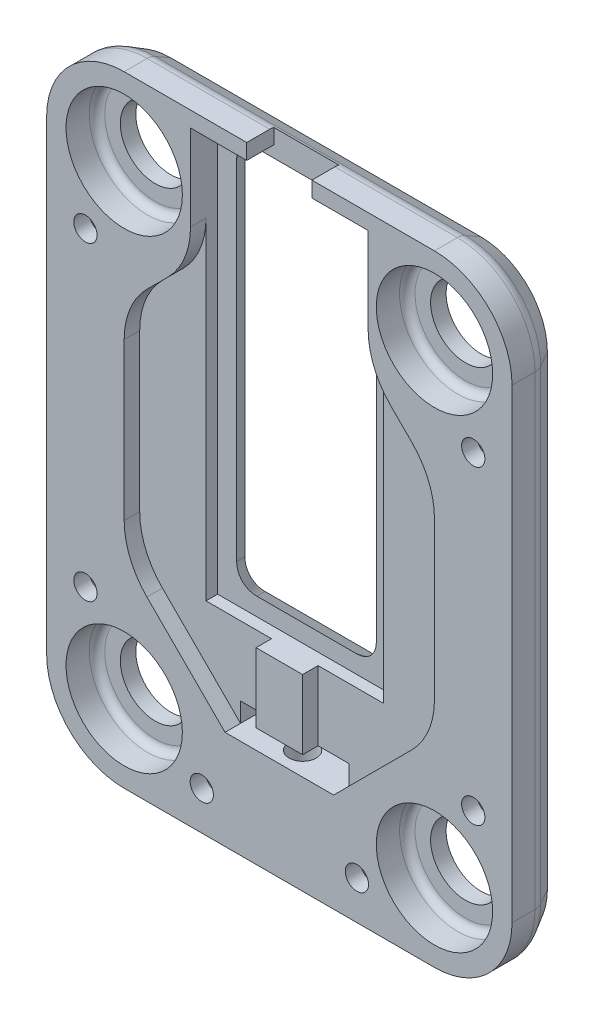
from build123d import *
from OCP.BRepFilletAPI import BRepFilletAPI_MakeChamfer

# Parameters (mm, degrees)
BOSS_EXTRUDE1_DEPTH                                 = 6
CHAMFER1_SIZE                                       = 2.5
CHAMFER1_SIZE2                                      = 1.443375673
FILLET1_R                                           = 2
SKETCH10_R                                          = 4.5
CUT_EXTRUDE1_DEPTH                                  = 6
SKETCH11_R                                          = 7.5
CUT_EXTRUDE2_DEPTH                                  = 4
CUT_EXTRUDE3_DEPTH                                  = 3.5
SKETCH13_W                                          = 18
SKETCH13_H                                          = 50
CUT_EXTRUDE4_DEPTH                                  = 84.643589248
CUT_EXTRUDE4_TAPER                                  = -30
FILLET2_R                                           = 3
CBORE_FOR_M5_HEX_SOCKET_HEAD_CAP_SCREW2_D           = 3
CBORE_FOR_M5_HEX_SOCKET_HEAD_CAP_SCREW2_CBORE_D     = 4
CBORE_FOR_M5_HEX_SOCKET_HEAD_CAP_SCREW2_CBORE_DEPTH = 4
CHAMFER2_SIZE                                       = 2.5
CHAMFER2_SIZE2                                      = 0.440817452
FILLET3_R                                           = 1
SKETCH24_W                                          = 14
SKETCH24_H                                          = 2.5
CUT_EXTRUDE5_DEPTH                                  = 84.785440399
M4_TAPPED_HOLE1_D                                   = 3.5
M4_TAPPED_HOLE1_DEPTH                               = 12.75
CUT_EXTRUDE6_DEPTH                                  = 2
FILLET4_R                                           = 10


with BuildPart() as part:
    # Sketch2 → Boss-Extrude1 (new body)
    with BuildSketch(Plane.XY):
        with BuildLine():
            Line((-20, 2), (20, 2))
            ThreePointArc((20, 2), (27.071067812, -0.928932188), (30, -8))
            Line((30, -8), (30, -68))
            ThreePointArc((30, -68), (27.071067812, -75.071067812), (20, -78))
            Line((20, -78), (-20, -78))
            ThreePointArc((-20, -78), (-27.071067812, -75.071067812), (-30, -68))
            Line((-30, -68), (-30, -8))
            ThreePointArc((-30, -8), (-27.071067812, -0.928932188), (-20, 2))
        make_face()
    extrude(amount=BOSS_EXTRUDE1_DEPTH)

    # Chamfer1: one chamfer whose edges measure the first distance from different faces: ONE call of the kernel's chamfer builder (chamfer() names one face for all edges)
    chamfer1_edges_1 = [part.edges().sort_by_distance(p)[0] for p in [
        (0, -78, 0),
    ]]
    chamfer1_side_1 = [part.faces().sort_by_distance(p)[0] for p in [
        (0, -78, 3),
    ]]
    chamfer1_edges_2 = [part.edges().sort_by_distance(p)[0] for p in [
        (-27.071067812, -75.071067812, 0),
    ]]
    chamfer1_side_2 = [part.faces().sort_by_distance(p)[0] for p in [
        (-27.071067812, -75.071067812, 3),
    ]]
    chamfer1_edges_3 = [part.edges().sort_by_distance(p)[0] for p in [
        (-30, -38, 0),
    ]]
    chamfer1_side_3 = [part.faces().sort_by_distance(p)[0] for p in [
        (-30, -38, 3),
    ]]
    chamfer1_edges_4 = [part.edges().sort_by_distance(p)[0] for p in [
        (-27.071067812, -0.928932188, 0),
    ]]
    chamfer1_side_4 = [part.faces().sort_by_distance(p)[0] for p in [
        (-27.071067812, -0.928932188, 3),
    ]]
    chamfer1_edges_5 = [part.edges().sort_by_distance(p)[0] for p in [
        (0, 2, 0),
    ]]
    chamfer1_side_5 = [part.faces().sort_by_distance(p)[0] for p in [
        (0, 2, 3),
    ]]
    chamfer1_edges_6 = [part.edges().sort_by_distance(p)[0] for p in [
        (27.071067812, -0.928932188, 0),
    ]]
    chamfer1_side_6 = [part.faces().sort_by_distance(p)[0] for p in [
        (27.071067812, -0.928932188, 3),
    ]]
    chamfer1_edges_7 = [part.edges().sort_by_distance(p)[0] for p in [
        (30, -38, 0),
    ]]
    chamfer1_side_7 = [part.faces().sort_by_distance(p)[0] for p in [
        (30, -38, 3),
    ]]
    chamfer1_edges_8 = [part.edges().sort_by_distance(p)[0] for p in [
        (27.071067812, -75.071067812, 0),
    ]]
    chamfer1_side_8 = [part.faces().sort_by_distance(p)[0] for p in [
        (27.071067812, -75.071067812, 3),
    ]]
    chamfer1 = BRepFilletAPI_MakeChamfer(part.part.solid().wrapped)
    for e in chamfer1_edges_1:
        chamfer1.Add(CHAMFER1_SIZE, CHAMFER1_SIZE2, e.wrapped, chamfer1_side_1[0].wrapped)  # the first distance lies on this face
    for e in chamfer1_edges_2:
        chamfer1.Add(CHAMFER1_SIZE, CHAMFER1_SIZE2, e.wrapped, chamfer1_side_2[0].wrapped)  # the first distance lies on this face
    for e in chamfer1_edges_3:
        chamfer1.Add(CHAMFER1_SIZE, CHAMFER1_SIZE2, e.wrapped, chamfer1_side_3[0].wrapped)  # the first distance lies on this face
    for e in chamfer1_edges_4:
        chamfer1.Add(CHAMFER1_SIZE, CHAMFER1_SIZE2, e.wrapped, chamfer1_side_4[0].wrapped)  # the first distance lies on this face
    for e in chamfer1_edges_5:
        chamfer1.Add(CHAMFER1_SIZE, CHAMFER1_SIZE2, e.wrapped, chamfer1_side_5[0].wrapped)  # the first distance lies on this face
    for e in chamfer1_edges_6:
        chamfer1.Add(CHAMFER1_SIZE, CHAMFER1_SIZE2, e.wrapped, chamfer1_side_6[0].wrapped)  # the first distance lies on this face
    for e in chamfer1_edges_7:
        chamfer1.Add(CHAMFER1_SIZE, CHAMFER1_SIZE2, e.wrapped, chamfer1_side_7[0].wrapped)  # the first distance lies on this face
    for e in chamfer1_edges_8:
        chamfer1.Add(CHAMFER1_SIZE, CHAMFER1_SIZE2, e.wrapped, chamfer1_side_8[0].wrapped)  # the first distance lies on this face
    add(Compound.cast(chamfer1.Shape()), mode=Mode.REPLACE)

    # Fillet1
    fillet1_edges = [part.edges().sort_by_distance(p)[0] for p in [
        (0, -78, 2.5),
        (27.071067812, -75.071067812, 2.5),
        (-27.071067812, -75.071067812, 2.5),
        (30, -38, 2.5),
        (-30, -38, 2.5),
        (27.071067812, -0.928932188, 2.5),
        (-27.071067812, -0.928932188, 2.5),
        (0, 2, 2.5),
    ]]
    fillet(fillet1_edges, radius=FILLET1_R)

    # Sketch10 → Cut-Extrude1 (cut)
    with BuildSketch(Plane.XY.offset(6)):
        with Locations((-20, -8)):
            Circle(SKETCH10_R)
        with Locations((20, -8)):
            Circle(SKETCH10_R)
        with Locations((20, -68)):
            Circle(SKETCH10_R)
        with Locations((-20, -68)):
            Circle(SKETCH10_R)
    extrude(amount=-CUT_EXTRUDE1_DEPTH, mode=Mode.SUBTRACT)

    # Sketch11 → Cut-Extrude2 (cut)
    with BuildSketch(Plane.XY.offset(6)):
        with Locations((-20, -8)):
            Circle(SKETCH11_R)
        with Locations((20, -8)):
            Circle(SKETCH11_R)
        with Locations((20, -68)):
            Circle(SKETCH11_R)
        with Locations((-20, -68)):
            Circle(SKETCH11_R)
    extrude(amount=-CUT_EXTRUDE2_DEPTH, mode=Mode.SUBTRACT)

    # Sketch12 → Cut-Extrude3 (cut)
    with BuildSketch(Plane.XY.offset(6)):
        Polygon((-4.2, 2), (-4.2, 0), (-11.45, 0), (-11.45, -53.8), (11.45, -53.8), (11.45, 0), (4.2, 0), (4.2, 2), align=None)
    extrude(amount=-CUT_EXTRUDE3_DEPTH, mode=Mode.SUBTRACT)

    # Sketch13 → Cut-Extrude4 (cut, through all)
    with BuildSketch(Plane.XY.offset(2.5)):
        with Locations((0, -26.5)):
            Rectangle(SKETCH13_W, SKETCH13_H)
    extrude(amount=-CUT_EXTRUDE4_DEPTH, taper=CUT_EXTRUDE4_TAPER, mode=Mode.SUBTRACT)

    # Fillet2
    fillet2_edges = [part.edges().sort_by_distance(p)[0] for p in [
        (-9.721687836, -52.221687836, 1.25),
        (-9.721687836, -0.778312164, 1.25),
        (9.721687836, -0.778312164, 1.25),
        (9.721687836, -52.221687836, 1.25),
    ]]
    fillet(fillet2_edges, radius=FILLET2_R)

    # CBORE for M5 Hex Socket Head Cap Screw2 (through all)
    with Locations(Plane(origin=(0, 0, 0), x_dir=(-1, 0, 0), z_dir=(0, 0, -1))):
        with Locations((-25, -18), (25, -18), (-10, -73), (10, -73), (25, -58), (-25, -58)):
            CounterBoreHole(CBORE_FOR_M5_HEX_SOCKET_HEAD_CAP_SCREW2_D / 2, CBORE_FOR_M5_HEX_SOCKET_HEAD_CAP_SCREW2_CBORE_D / 2, CBORE_FOR_M5_HEX_SOCKET_HEAD_CAP_SCREW2_CBORE_DEPTH)

    # Chamfer2: one chamfer whose edges measure the first distance from different faces: ONE call of the kernel's chamfer builder (chamfer() names one face for all edges)
    chamfer2_edges_1 = [part.edges().sort_by_distance(p)[0] for p in [
        (-8, -73, 0),
    ]]
    chamfer2_side_1 = [part.faces().sort_by_distance(p)[0] for p in [
        (-8, -73, 2),
    ]]
    chamfer2_edges_2 = [part.edges().sort_by_distance(p)[0] for p in [
        (12, -73, 0),
    ]]
    chamfer2_side_2 = [part.faces().sort_by_distance(p)[0] for p in [
        (12, -73, 2),
    ]]
    chamfer2_edges_3 = [part.edges().sort_by_distance(p)[0] for p in [
        (-23, -18, 0),
    ]]
    chamfer2_side_3 = [part.faces().sort_by_distance(p)[0] for p in [
        (-23, -18, 2),
    ]]
    chamfer2_edges_4 = [part.edges().sort_by_distance(p)[0] for p in [
        (27, -18, 0),
    ]]
    chamfer2_side_4 = [part.faces().sort_by_distance(p)[0] for p in [
        (27, -18, 2),
    ]]
    chamfer2 = BRepFilletAPI_MakeChamfer(part.part.solid().wrapped)
    for e in chamfer2_edges_1:
        chamfer2.Add(CHAMFER2_SIZE, CHAMFER2_SIZE2, e.wrapped, chamfer2_side_1[0].wrapped)  # the first distance lies on this face
    for e in chamfer2_edges_2:
        chamfer2.Add(CHAMFER2_SIZE, CHAMFER2_SIZE2, e.wrapped, chamfer2_side_2[0].wrapped)  # the first distance lies on this face
    for e in chamfer2_edges_3:
        chamfer2.Add(CHAMFER2_SIZE, CHAMFER2_SIZE2, e.wrapped, chamfer2_side_3[0].wrapped)  # the first distance lies on this face
    for e in chamfer2_edges_4:
        chamfer2.Add(CHAMFER2_SIZE, CHAMFER2_SIZE2, e.wrapped, chamfer2_side_4[0].wrapped)  # the first distance lies on this face
    add(Compound.cast(chamfer2.Shape()), mode=Mode.REPLACE)

    # Fillet3
    fillet3_edges = [part.edges().sort_by_distance(p)[0] for p in [
        (-27.5, -68, 2),
        (12.5, -68, 2),
        (12.5, -8, 2),
        (-27.5, -8, 2),
    ]]
    fillet(fillet3_edges, radius=FILLET3_R)

    # Sketch24 → Cut-Extrude5 (cut, through all)
    with BuildSketch(Plane.XY.offset(6)):
        with Locations((0, -64)):
            Rectangle(SKETCH24_W, SKETCH24_H)
    extrude(amount=-CUT_EXTRUDE5_DEPTH, mode=Mode.SUBTRACT)

    # M4 Tapped Hole1
    with Locations(Plane(origin=(0, -78, 0), x_dir=(-1, 0, 0), z_dir=(0, -1, 0))):
        with Locations((0, -3)):
            Hole(M4_TAPPED_HOLE1_D / 2, depth=M4_TAPPED_HOLE1_DEPTH)

    # Sketch27 → Cut-Extrude6 (cut)
    with BuildSketch(Plane.XY.offset(6)):
        Polygon((3, -10.75), (7, -10.75), (20, -23.75), (20, -52.25), (7, -65.25), (7, -64.290555577), (3, -64.290555577), align=None)
        Polygon((-3, -64.290555577), (-3, -10.75), (-7, -10.75), (-20, -23.75), (-20, -52.25), (-7, -65.25), (-7, -64.290555577), align=None)
    extrude(amount=-CUT_EXTRUDE6_DEPTH, mode=Mode.SUBTRACT)

    # Fillet4
    fillet4_edges = [part.edges().sort_by_distance(p)[0] for p in [
        (-11.45, -15.2, 5),
        (11.45, -15.2, 5),
        (20, -23.75, 5),
        (20, -52.25, 5),
        (-20, -23.75, 5),
        (-20, -52.25, 5),
    ]]
    fillet(fillet4_edges, radius=FILLET4_R)


solid = part.part
